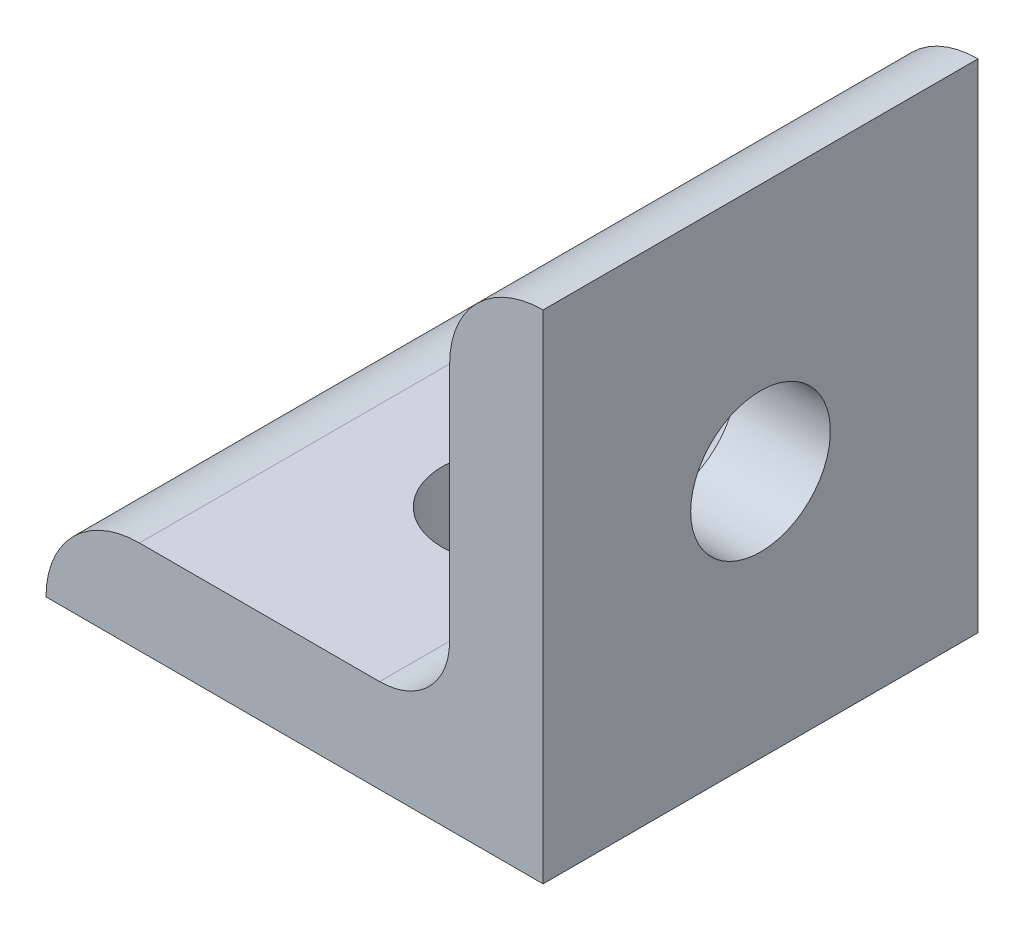
from build123d import *

# Parameters (mm, degrees)
EXTRUDE1_DEPTH     = 11.1125
SKETCH2_R          = 3.5687
CUT_EXTRUDE1_DEPTH = 5.7752
SKETCH3_R          = 3.5687
CUT_EXTRUDE2_DEPTH = 5.7752


with BuildPart() as part:
    # Sketch1 → Extrude1 (new body, symmetric)
    with BuildSketch(Plane.XY):
        with BuildLine():
            Line((0, 0), (0, 25.4))
            ThreePointArc((0, 25.4), (-3.376576302, 24.001376302), (-4.7752, 20.6248))
            Line((-4.7752, 20.6248), (-4.7752, 8.3566))
            ThreePointArc((-4.7752, 8.3566), (-5.824167774, 5.824167774), (-8.3566, 4.7752))
            Line((-8.3566, 4.7752), (-20.6248, 4.7752))
            ThreePointArc((-20.6248, 4.7752), (-24.001376302, 3.376576302), (-25.4, 0))
            Line((-25.4, 0), (0, 0))
        make_face()
    extrude(amount=EXTRUDE1_DEPTH, both=True)

    # Sketch2 → Cut-Extrude1 (cut, through all)
    with BuildSketch(Plane(origin=(0, 4.7752, 0), x_dir=(1, 0, 0), z_dir=(0, 1, 0))):
        with Locations((-12.7, 0)):
            Circle(SKETCH2_R)
    extrude(amount=-CUT_EXTRUDE1_DEPTH, mode=Mode.SUBTRACT)

    # Sketch3 → Cut-Extrude2 (cut, through all)
    with BuildSketch(Plane.ZY.offset(4.7752)):
        with Locations((0, 12.7)):
            Circle(SKETCH3_R)
    extrude(amount=-CUT_EXTRUDE2_DEPTH, mode=Mode.SUBTRACT)


solid = part.part
